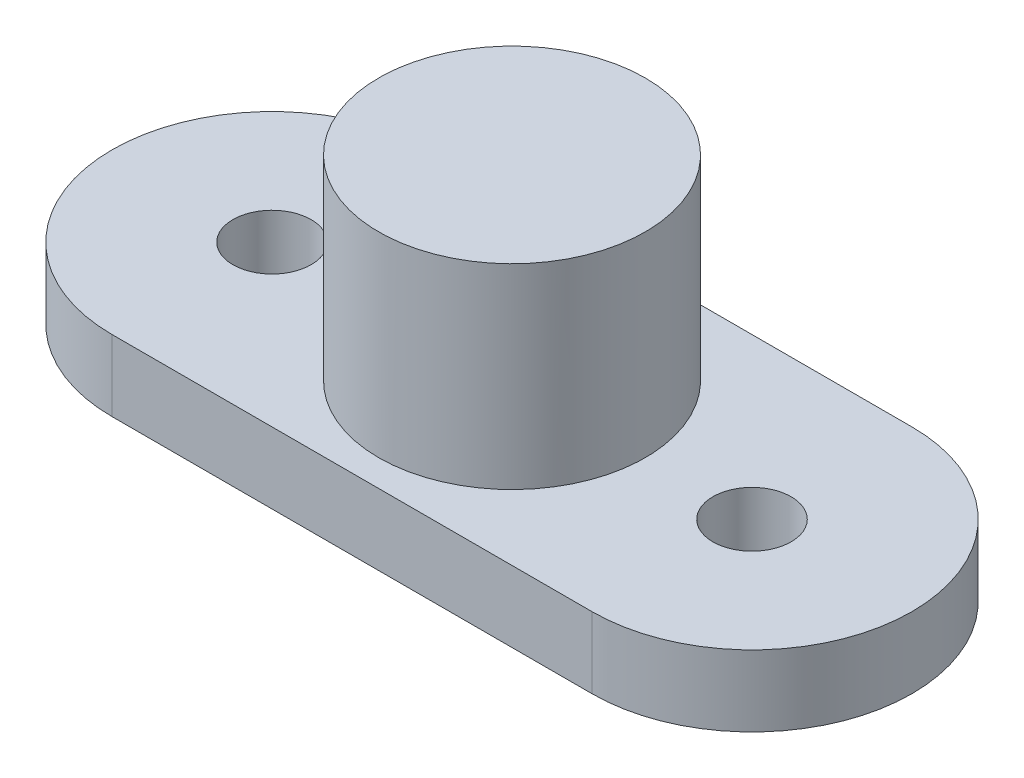
from build123d import *

# Parameters (mm, degrees)
SKETCH1_R           = 1.1
SKETCH1_R_2         = 3.75
BOSS_EXTRUDE3_DEPTH = 2
SKETCH3_R           = 3.75
BOSS_EXTRUDE4_DEPTH = 7.5


with BuildPart() as part:
    # Sketch1 → Boss-Extrude3 (new body)
    with BuildSketch(Plane(origin=(0, 0, 0), x_dir=(1, 0, 0), z_dir=(0, 1, 0))):
        with BuildLine():
            Line((-6.75, 4.499502967), (6.75, 4.499502967))
            ThreePointArc((6.75, 4.499502967), (11.249502967, 0), (6.75, -4.499502967))
            Line((6.75, -4.499502967), (-6.75, -4.499502967))
            ThreePointArc((-6.75, -4.499502967), (-11.249502967, 0), (-6.75, 4.499502967))
        make_face()
        with Locations((-6.75, 0)):
            Circle(SKETCH1_R, mode=Mode.SUBTRACT)
        with Locations((6.75, 0)):
            Circle(SKETCH1_R, mode=Mode.SUBTRACT)
        Circle(SKETCH1_R_2, mode=Mode.SUBTRACT)
    extrude(amount=BOSS_EXTRUDE3_DEPTH)

    # Sketch3 → Boss-Extrude4 (add)
    with BuildSketch(Plane.XZ):
        Circle(SKETCH3_R)
    extrude(amount=-BOSS_EXTRUDE4_DEPTH)


solid = part.part
